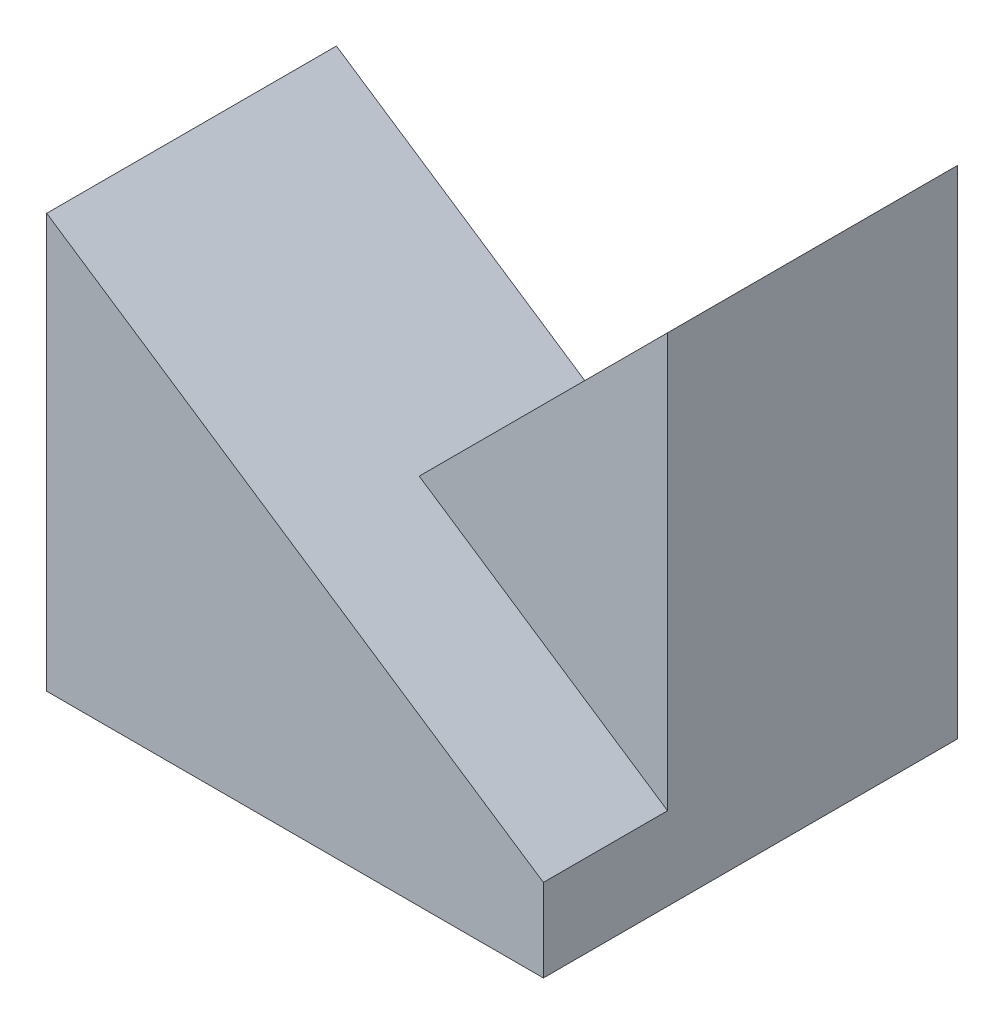
from build123d import *

# Parameters (mm, degrees)
SKETCH1_W           = 6
SKETCH1_H           = 5
BOSS_EXTRUDE1_DEPTH = 6
CUT_EXTRUDE1_DEPTH  = 3.5
CUT_EXTRUDE2_DEPTH  = 1.5
CUT_EXTRUDE3_DEPTH  = 3.5
CUT_EXTRUDE4_DEPTH  = 1.5


with BuildPart() as part:
    # Sketch1 → Boss-Extrude1 (new body)
    with BuildSketch(Plane(origin=(0, 0, 0), x_dir=(1, 0, 0), z_dir=(0, 1, 0))):
        Rectangle(SKETCH1_W, SKETCH1_H)
    extrude(amount=BOSS_EXTRUDE1_DEPTH)

    # Sketch2 → Cut-Extrude1 (cut)
    with BuildSketch(Plane.XY.offset(2.5)):
        Polygon((-3, 5), (0, 3), (0, 6), (-3, 6), align=None)
    extrude(amount=-CUT_EXTRUDE1_DEPTH, mode=Mode.SUBTRACT)

    # Sketch4 → Cut-Extrude2 (cut)
    with BuildSketch(Plane.XY.offset(2.5)):
        Polygon((0, 3), (3, 1), (3, 6), (0, 6), align=None)
    extrude(amount=-CUT_EXTRUDE2_DEPTH, mode=Mode.SUBTRACT)

    # Sketch5 → Cut-Extrude3 (cut)
    with BuildSketch(Plane(origin=(0, 0, -2.5), x_dir=(-1, 0, 0), z_dir=(0, 0, -1))):
        Polygon((0, 6), (-3, 6), (0, 3), align=None)
    extrude(amount=-CUT_EXTRUDE3_DEPTH, mode=Mode.SUBTRACT)

    # Sketch6 → Cut-Extrude4 (cut)
    with BuildSketch(Plane(origin=(0, 0, -2.5), x_dir=(-1, 0, 0), z_dir=(0, 0, -1))):
        Polygon((0, 3), (3, 0), (3, 6), (0, 6), align=None)
    extrude(amount=-CUT_EXTRUDE4_DEPTH, mode=Mode.SUBTRACT)


solid = part.part
